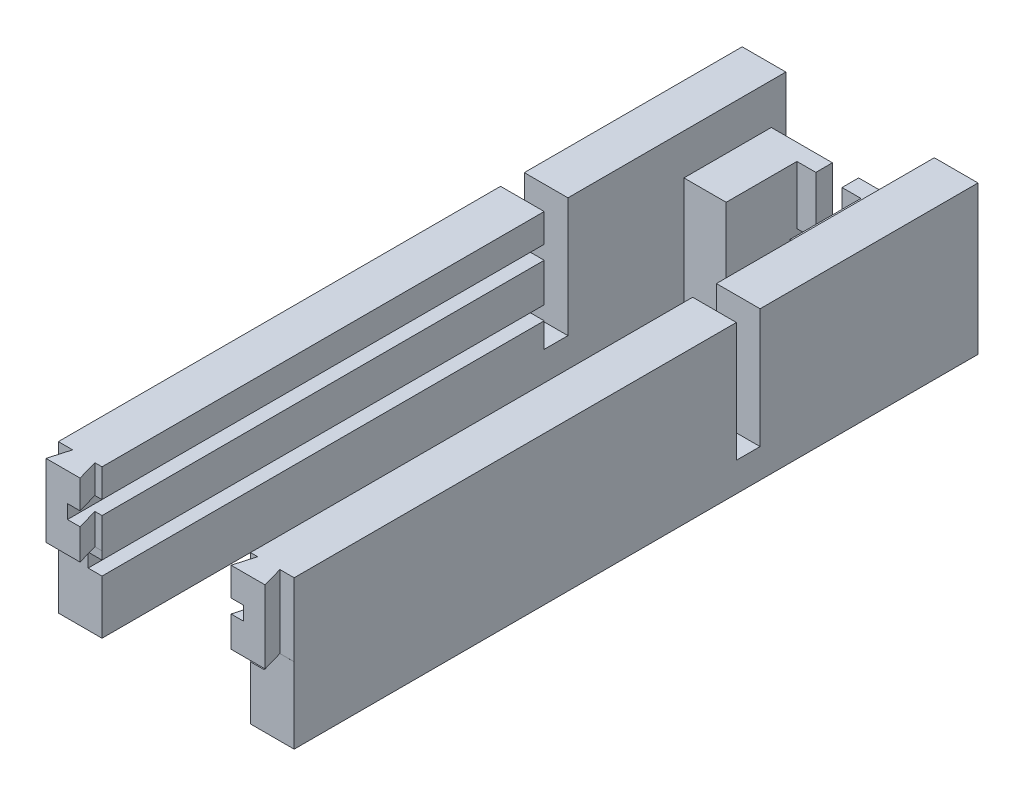
from build123d import *

# Parameters (mm, degrees)
SKETCH1_W           = 242
SKETCH1_H           = 51
BOSS_EXTRUDE1_DEPTH = 15
SKETCH26_W          = 30
SKETCH26_H          = 37
BOSS_EXTRUDE3_DEPTH = 29.5
SKETCH28_W          = 15
SKETCH28_H          = 9.75
BOSS_EXTRUDE5_DEPTH = 4.5
SKETCH29_W          = 5.7
SKETCH29_H          = 20
BOSS_EXTRUDE6_DEPTH = 6.5
CUT_EXTRUDE8_DEPTH  = 25
SKETCH13_W          = 15
SKETCH13_H          = 7.11
CUT_EXTRUDE9_DEPTH  = 26
SKETCH17_W          = 15
SKETCH17_H          = 8.15
CUT_EXTRUDE10_DEPTH = 41
SKETCH7_W           = 4.75
SKETCH7_H           = 4.75
CUT_EXTRUDE5_DEPTH  = 165


with BuildPart() as part:
    # Sketch1 → Boss-Extrude1 (new body)
    with BuildSketch(Plane(origin=(0, 0, 0), x_dir=(0, 0, -1), z_dir=(1, 0, 0))):
        with Locations((56.437921078, 5.057266603)):
            Rectangle(SKETCH1_W, SKETCH1_H)
    extrude(amount=BOSS_EXTRUDE1_DEPTH)

    # Sketch26 → Boss-Extrude3 (add)
    with BuildSketch(Plane.ZY):
        with Locations((-157.437921078, -1.942733397)):
            Rectangle(SKETCH26_W, SKETCH26_H)
    extrude(amount=-BOSS_EXTRUDE3_DEPTH)

    # Sketch28 → Boss-Extrude5 (add)
    with BuildSketch(Plane(origin=(29.5, 0, 0), x_dir=(0, 0, -1), z_dir=(1, 0, 0))):
        with Locations((154.541661602, -15.567733397)):
            Rectangle(SKETCH28_W, SKETCH28_H)
    extrude(amount=BOSS_EXTRUDE5_DEPTH)

    # Sketch29 → Boss-Extrude6 (add)
    with BuildSketch(Plane(origin=(29.5, 0, 0), x_dir=(0, 0, -1), z_dir=(1, 0, 0))):
        with Locations((169.587921078, 6.557266603)):
            Rectangle(SKETCH29_W, SKETCH29_H)
    extrude(amount=BOSS_EXTRUDE6_DEPTH)

    # Sketch12 → Cut-Extrude8 (cut)
    with BuildSketch(Plane(origin=(0, 30.557266603, 0), x_dir=(1, 0, 0), z_dir=(0, 1, 0))):
        Polygon((0, -57.448742372), (4.909716433, -57.448742372), (2.87, -64.562078922), (0, -64.562078922), align=None)
        Polygon((15, -57.448742372), (15, -64.562078922), (14.57, -64.562078922), (12.530283567, -57.448742372), align=None)
    extrude(amount=-CUT_EXTRUDE8_DEPTH, mode=Mode.SUBTRACT)

    # Sketch13 → Cut-Extrude9 (cut)
    with BuildSketch(Plane.XZ.offset(20.442733397)):
        with Locations((7.5, 61.007078922)):
            Rectangle(SKETCH13_W, SKETCH13_H)
    extrude(amount=-CUT_EXTRUDE9_DEPTH, mode=Mode.SUBTRACT)

    # Sketch17 → Cut-Extrude10 (cut)
    with BuildSketch(Plane(origin=(0, 30.557266603, 0), x_dir=(1, 0, 0), z_dir=(0, 1, 0))):
        with Locations((7.5, 98.512921078)):
            Rectangle(SKETCH17_W, SKETCH17_H)
    extrude(amount=-CUT_EXTRUDE10_DEPTH, mode=Mode.SUBTRACT)

    # Sketch7 → Cut-Extrude5 (cut)
    with BuildSketch(Plane(origin=(0, 0, -94.437921078), x_dir=(-1, 0, 0), z_dir=(0, 0, -1))):
        with Locations((-12.625, 0.432266603)):
            Rectangle(SKETCH7_W, SKETCH7_H)
        with Locations((-12.625, 18.432266603)):
            Rectangle(SKETCH7_W, SKETCH7_H)
    extrude(amount=-CUT_EXTRUDE5_DEPTH, mode=Mode.SUBTRACT)


with BuildPart() as body_2:
    # Mirror4: mirrored copy
    add(part.part.mirror(Plane(origin=(40.5, 0, 0), x_dir=(0, 0, 1), z_dir=(1, 0, 0))))


solid = Compound([part.part, body_2.part])
